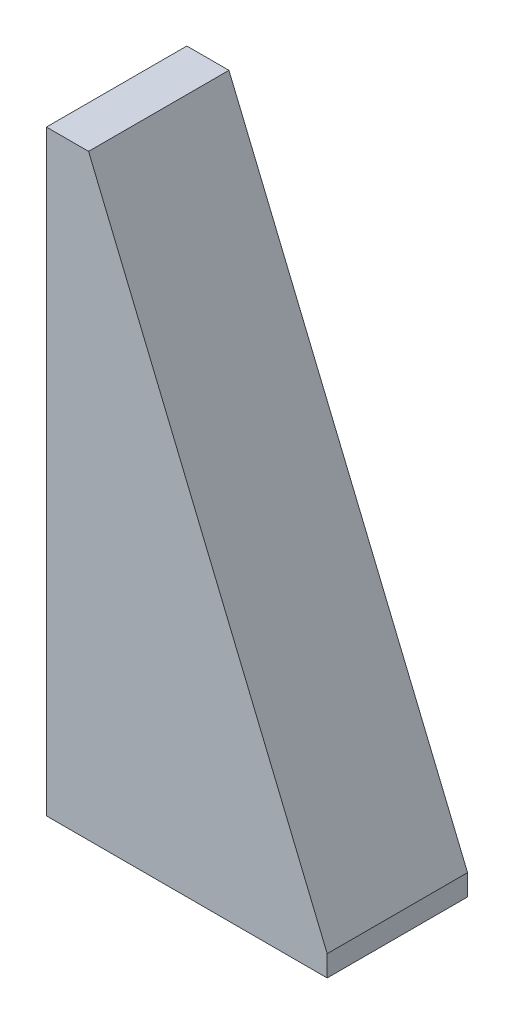
from build123d import *

# Parameters (mm, degrees)
BOSS_EXTRUDE1_DEPTH = 10
SKETCH2_W           = 20
SKETCH2_H           = 1.5
BOSS_EXTRUDE2_DEPTH = 10


with BuildPart() as part:
    # Sketch1 → Boss-Extrude1 (new body)
    with BuildSketch(Plane.XY):
        Polygon((0, 0), (0, 41), (3, 41), (20, 0), align=None)
    extrude(amount=BOSS_EXTRUDE1_DEPTH)

    # Sketch2 → Boss-Extrude2 (add)
    with BuildSketch(Plane.XY.offset(10)):
        with Locations((10, -0.75)):
            Rectangle(SKETCH2_W, SKETCH2_H)
    extrude(amount=-BOSS_EXTRUDE2_DEPTH)


solid = part.part
